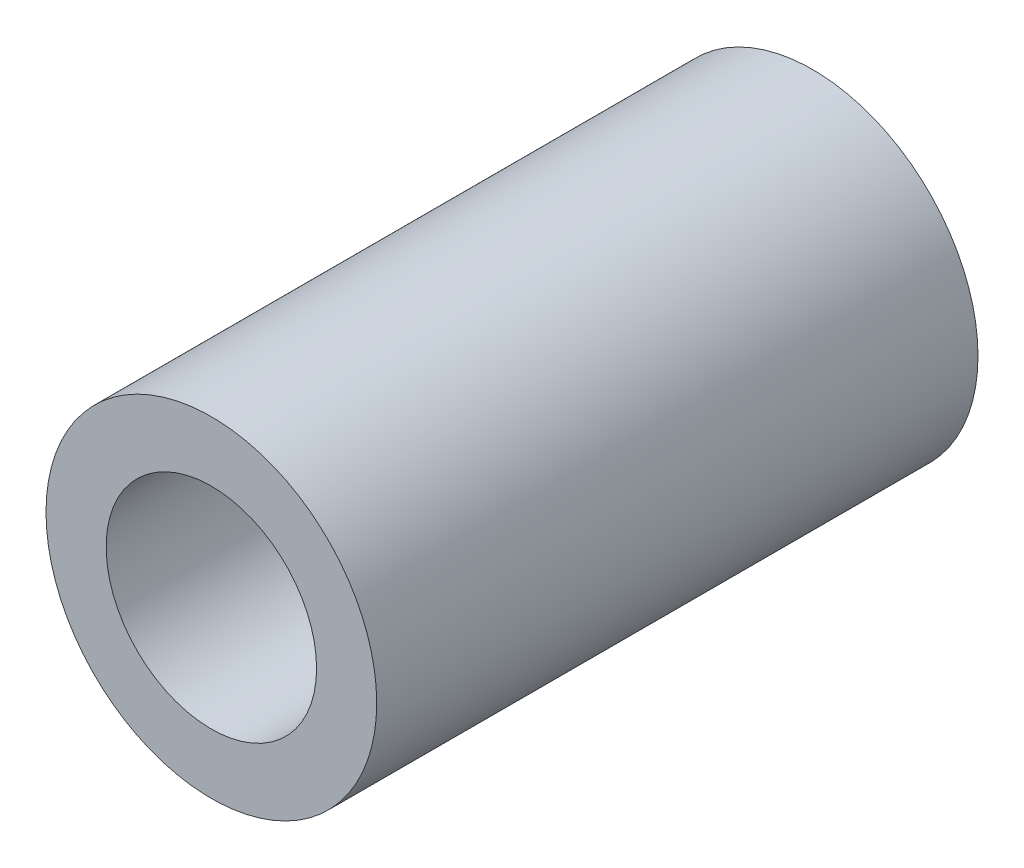
from build123d import *

# Parameters (mm, degrees)
SKETCH1_R           = 2.75
SKETCH1_R_2         = 1.75
BOSS_EXTRUDE1_DEPTH = 10


with BuildPart() as part:
    # Sketch1 → Boss-Extrude1 (new body)
    with BuildSketch(Plane.XY):
        with Locations((-103.020051755, 119.364927073)):
            Circle(SKETCH1_R)
        with Locations((-103.020051755, 119.364927073)):
            Circle(SKETCH1_R_2, mode=Mode.SUBTRACT)
    extrude(amount=BOSS_EXTRUDE1_DEPTH)


solid = part.part
